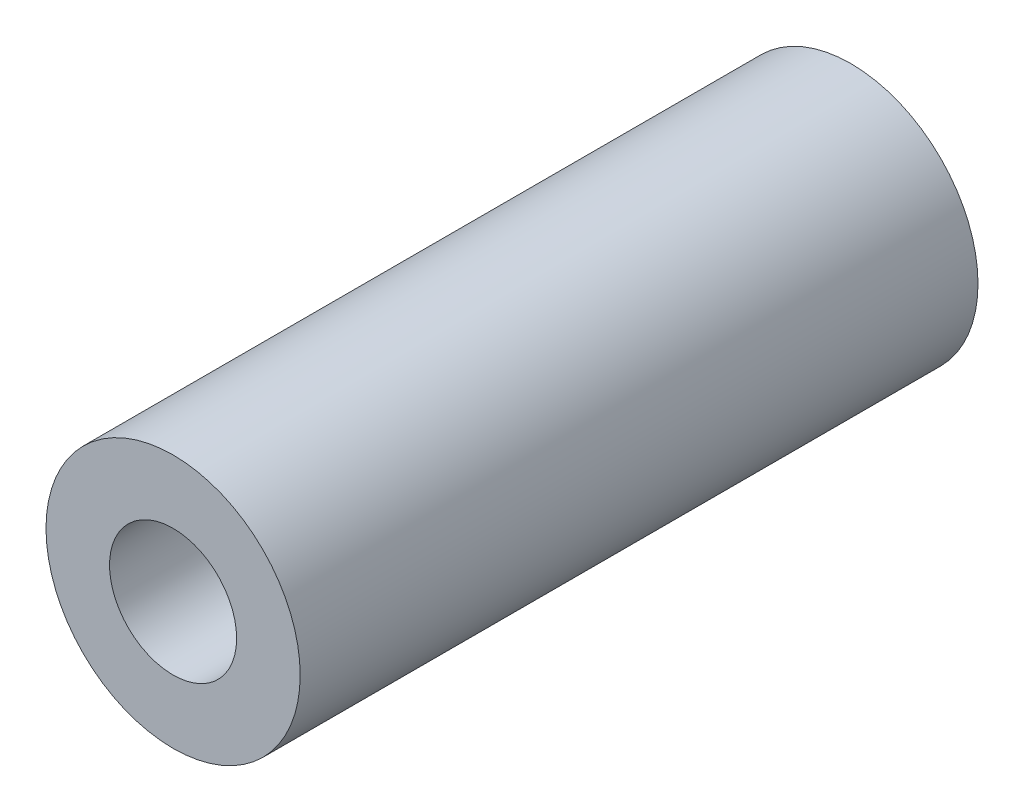
from build123d import *

# Parameters (mm, degrees)
ESQUISSE1_R   = 3
ESQUISSE1_R_2 = 1.5
MAIN_DEPTH    = 16


with BuildPart() as part:
    # Esquisse1 → Main (new body)
    with BuildSketch(Plane.XY):
        Circle(ESQUISSE1_R)
        Circle(ESQUISSE1_R_2, mode=Mode.SUBTRACT)
    extrude(amount=MAIN_DEPTH)


solid = part.part
